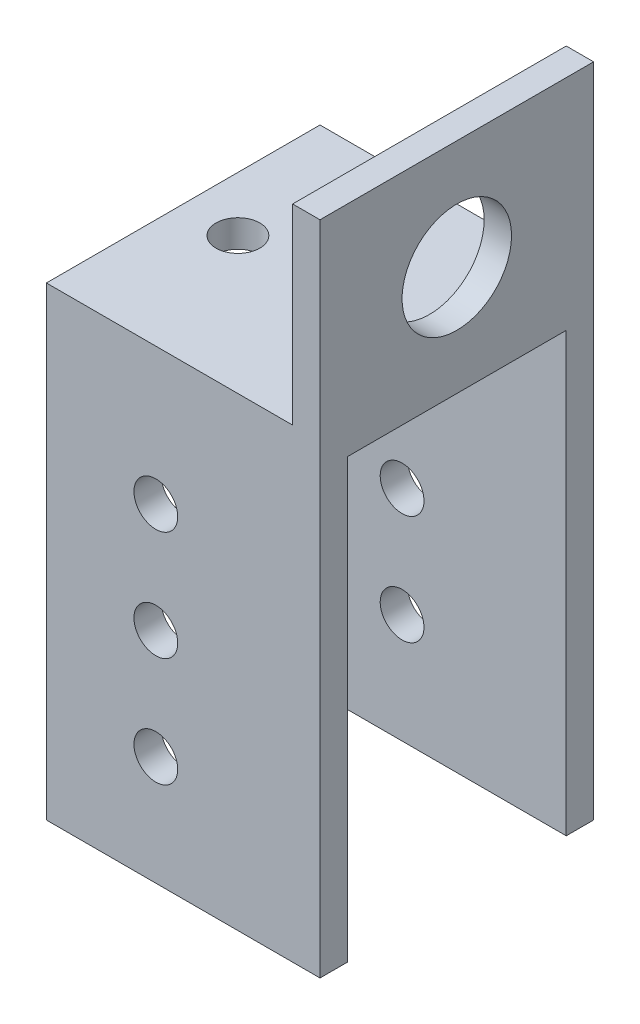
from build123d import *

# Parameters (mm, degrees)
BOSS_EXTRUDE2_DEPTH = 31.75
SKETCH10_W          = 25.4
SKETCH10_H          = 50.8
CUT_EXTRUDE4_DEPTH  = 32.75
SKETCH11_R          = 2.54
CUT_EXTRUDE5_DEPTH  = 3.175
SKETCH12_R          = 2.54
CUT_EXTRUDE6_DEPTH  = 31.75
SKETCH13_R          = 6.35
CUT_EXTRUDE7_DEPTH  = 3.175


with BuildPart() as part:
    # Sketch8 → Boss-Extrude2 (new body)
    with BuildSketch(Plane.XY):
        Polygon((-15.875, 15.875), (-15.875, -38.1), (15.875, -38.1), (15.875, 38.1), (12.7, 38.1), (12.7, 15.875), align=None)
    extrude(amount=BOSS_EXTRUDE2_DEPTH)

    # Sketch10 → Cut-Extrude4 (cut, through all)
    with BuildSketch(Plane.ZY.offset(15.875)):
        with Locations((15.875, -12.7)):
            Rectangle(SKETCH10_W, SKETCH10_H)
    extrude(amount=-CUT_EXTRUDE4_DEPTH, mode=Mode.SUBTRACT)

    # Sketch11 → Cut-Extrude5 (cut)
    with BuildSketch(Plane(origin=(0, 15.875, 0), x_dir=(1, 0, 0), z_dir=(0, 1, 0))):
        with Locations((-9.525, -15.875)):
            Circle(SKETCH11_R)
        with Locations((3.175, -15.875)):
            Circle(SKETCH11_R)
    extrude(amount=-CUT_EXTRUDE5_DEPTH, mode=Mode.SUBTRACT)

    # Sketch12 → Cut-Extrude6 (cut)
    with BuildSketch(Plane.XY.offset(31.75)):
        with Locations((-3.175, 0)):
            Circle(SKETCH12_R)
        with Locations((-3.175, -12.7)):
            Circle(SKETCH12_R)
        with Locations((-3.175, -25.4)):
            Circle(SKETCH12_R)
    extrude(amount=-CUT_EXTRUDE6_DEPTH, mode=Mode.SUBTRACT)

    # Sketch13 → Cut-Extrude7 (cut)
    with BuildSketch(Plane(origin=(15.875, 0, 0), x_dir=(0, 0, -1), z_dir=(1, 0, 0))):
        with Locations((-15.875, 25.4)):
            Circle(SKETCH13_R)
    extrude(amount=-CUT_EXTRUDE7_DEPTH, mode=Mode.SUBTRACT)


solid = part.part
